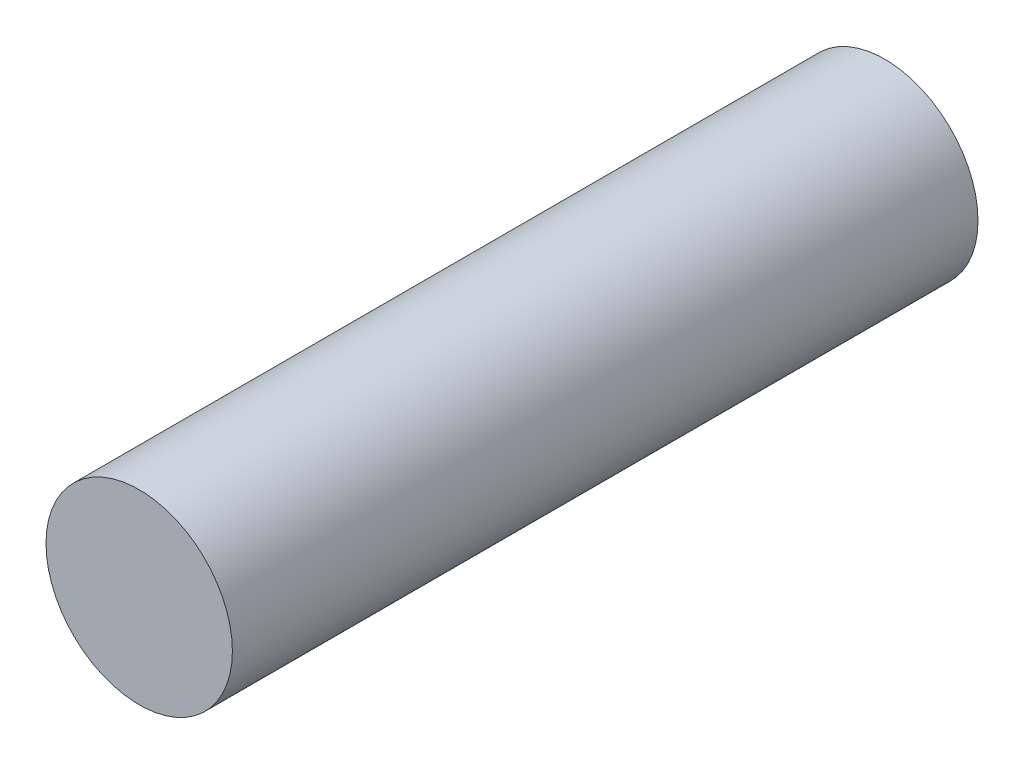
from build123d import *

# Parameters (mm, degrees)
SKETCH1_R           = 3.96875
BOSS_EXTRUDE1_DEPTH = 15.875


with BuildPart() as part:
    # Sketch1 → Boss-Extrude1 (new body, symmetric)
    with BuildSketch(Plane.XY):
        Circle(SKETCH1_R)
    extrude(amount=BOSS_EXTRUDE1_DEPTH, both=True)


solid = part.part
